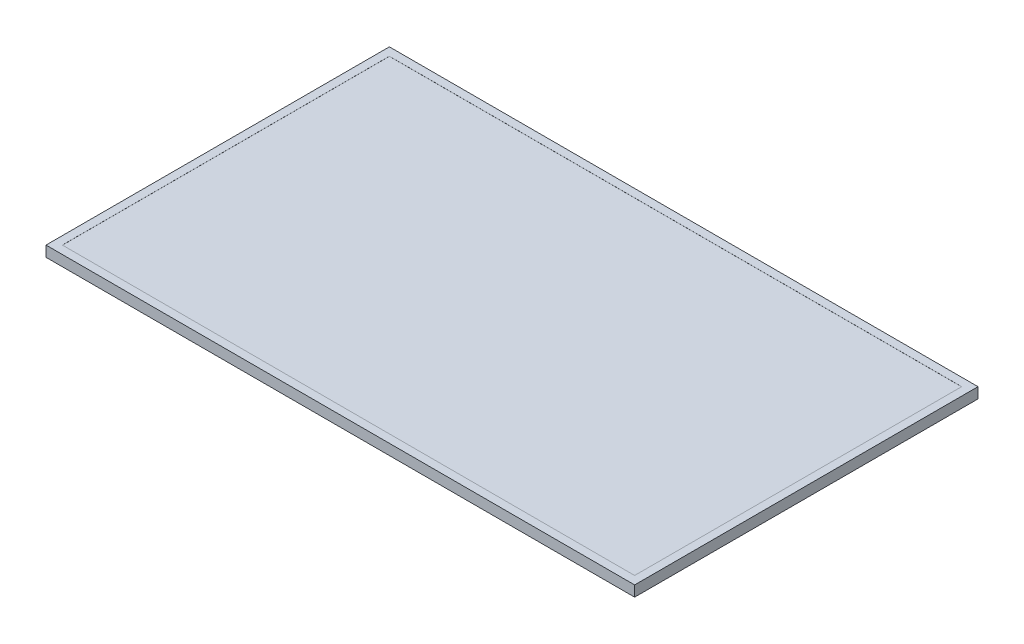
from build123d import *

# Parameters (mm, degrees)
SKETCH1_W           = 350
SKETCH1_H           = 200
BOSS_EXTRUDE3_DEPTH = 6.45
SKETCH1_4_W         = 360
SKETCH1_4_H         = 210
SKETCH1_4_W_2       = 350
SKETCH1_4_H_2       = 200
BOSS_EXTRUDE4_DEPTH = 6.5
SKETCH1_5_W         = 28
SKETCH1_5_H         = 7
BOSS_EXTRUDE5_DEPTH = 0.5


with BuildPart() as part:
    # Sketch1 → Boss-Extrude3 (new body)
    with BuildSketch(Plane(origin=(0, 0, 0), x_dir=(1, 0, 0), z_dir=(0, 1, 0))):
        Rectangle(SKETCH1_W, SKETCH1_H)
    extrude(amount=BOSS_EXTRUDE3_DEPTH)

    # Sketch1_4 → Boss-Extrude4 (add)
    with BuildSketch(Plane(origin=(0, 0, 0), x_dir=(1, 0, 0), z_dir=(0, 1, 0))):
        Rectangle(SKETCH1_4_W, SKETCH1_4_H)
        Rectangle(SKETCH1_4_W_2, SKETCH1_4_H_2, mode=Mode.SUBTRACT)
    extrude(amount=BOSS_EXTRUDE4_DEPTH)

    # Sketch1_5 → Boss-Extrude5 (add)
    with BuildSketch(Plane(origin=(0, 0, 0), x_dir=(1, 0, 0), z_dir=(0, 1, 0))):
        with Locations((61, -68.9)):
            Rectangle(SKETCH1_5_W, SKETCH1_5_H)
    extrude(amount=-BOSS_EXTRUDE5_DEPTH)


solid = part.part
